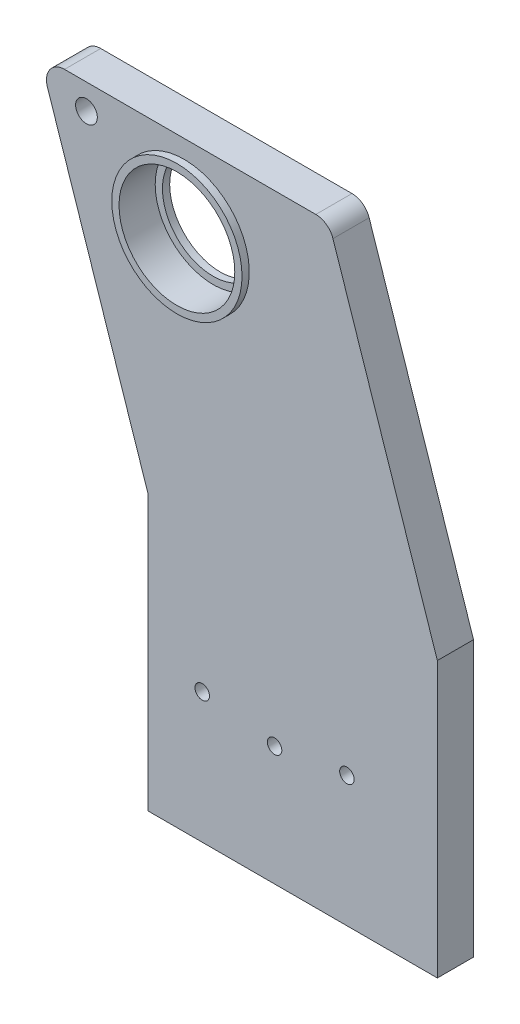
from build123d import *

# Parameters (mm, degrees)
SKETCH1_R           = 16
BOSS_EXTRUDE1_DEPTH = 10
SKETCH2_R           = 18
SKETCH2_R_2         = 16
BOSS_EXTRUDE2_DEPTH = 2
SKETCH3_R           = 2
CUT_EXTRUDE1_DEPTH  = 10
SKETCH4_R           = 2
CUT_EXTRUDE2_DEPTH  = 10
CUT_EXTRUDE3_REACH  = 14
SKETCH5_R           = 3
FILLET1_R           = 5
BOSS_EXTRUDE4_START = -2
SKETCH8_R           = 16
SKETCH8_R_2         = 14
BOSS_EXTRUDE4_DEPTH = 2


with BuildPart() as part:
    # Sketch1 → Boss-Extrude1 (new body)
    with BuildSketch(Plane.XY):
        Polygon((-40, 83), (-70, 83), (-40, -7), (-40, -83), (40, -83), (40, -7), (10, 83), align=None)
        with Locations((-30, 60)):
            Circle(SKETCH1_R, mode=Mode.SUBTRACT)
    extrude(amount=BOSS_EXTRUDE1_DEPTH)

    # Sketch2 → Boss-Extrude2 (add)
    with BuildSketch(Plane.XY.offset(10)):
        with Locations((-30, 60)):
            Circle(SKETCH2_R)
        with Locations((-30, 60)):
            Circle(SKETCH2_R_2, mode=Mode.SUBTRACT)
    extrude(amount=BOSS_EXTRUDE2_DEPTH)

    # Sketch3 → Cut-Extrude1 (cut)
    with BuildSketch(Plane(origin=(0, 0, 0), x_dir=(-1, 0, 0), z_dir=(0, 0, -1))):
        with Locations((-15, -47)):
            Circle(SKETCH3_R)
        with Locations((25, -47)):
            Circle(SKETCH3_R)
    extrude(amount=-CUT_EXTRUDE1_DEPTH, mode=Mode.SUBTRACT)

    # Sketch4 → Cut-Extrude2 (cut)
    with BuildSketch(Plane(origin=(0, 0, 0), x_dir=(-1, 0, 0), z_dir=(0, 0, -1))):
        with Locations((5, -50)):
            Circle(SKETCH4_R)
    extrude(amount=-CUT_EXTRUDE2_DEPTH, mode=Mode.SUBTRACT)

    # Sketch5 → Cut-Extrude3 (cut, up to next)
    with BuildSketch(Plane(origin=(0, 0, 0), x_dir=(-1, 0, 0), z_dir=(0, 0, -1)), mode=Mode.PRIVATE) as cut_extrude3_sk1:
        with Locations((57, 76)):
            Circle(SKETCH5_R)
    cut_extrude3_tool1 = extrude(cut_extrude3_sk1.sketch, amount=-CUT_EXTRUDE3_REACH, mode=Mode.PRIVATE) & part.part
    add(cut_extrude3_tool1.solids().sort_by_distance((-57, 76, 0))[0], mode=Mode.SUBTRACT)

    # Fillet1
    fillet1_edges = [part.edges().sort_by_distance(p)[0] for p in [
        (-70, 83, 5),
        (10, 83, 5),
    ]]
    fillet(fillet1_edges, radius=FILLET1_R)

    # Sketch8 → Boss-Extrude4 (add)
    with BuildSketch(Plane(origin=(0, 0, 0), x_dir=(-1, 0, 0), z_dir=(0, 0, -1)).offset(BOSS_EXTRUDE4_START)):
        with Locations((30, 60)):
            Circle(SKETCH8_R)
        with Locations((30, 60)):
            Circle(SKETCH8_R_2, mode=Mode.SUBTRACT)
    extrude(amount=BOSS_EXTRUDE4_DEPTH)


solid = part.part
